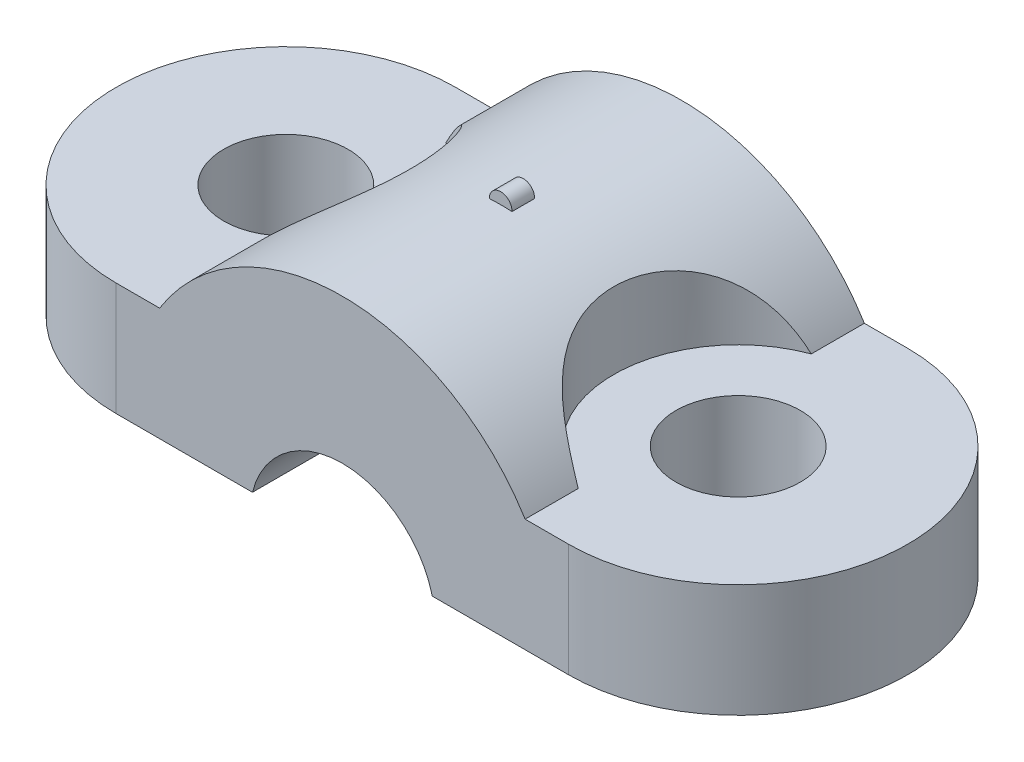
from build123d import *

# Parameters (mm, degrees)
BOSS_EXTRUDE1_DEPTH = 9.5
SKETCH1_3_R         = 2.75
BOSS_EXTRUDE2_DEPTH = 5
CUT_EXTRUDE2_DEPTH  = 25.929901725
BOSS_EXTRUDE3_DEPTH = 0.5


with BuildPart() as part:
    # Sketch1 → Boss-Extrude1 (new body)
    with BuildSketch(Plane(origin=(0, 0, 0), x_dir=(1, 0, 0), z_dir=(0, 1, 0))):
        with BuildLine():
            Line((8.08, 7.5), (-8.08, 7.5))
            Line((-8.08, 7.5), (-8.08, 5.153988747))
            ThreePointArc((-8.08, 5.153988747), (-4.5, 0), (-8.08, -5.153988747))
            Line((-8.08, -5.153988747), (-8.08, -7.5))
            Line((-8.08, -7.5), (8.08, -7.5))
            Line((8.08, -7.5), (8.08, -5.153988747))
            ThreePointArc((8.08, -5.153988747), (4.5, 0), (8.08, 5.153988747))
            Line((8.08, 5.153988747), (8.08, 7.5))
        make_face()
    extrude(amount=BOSS_EXTRUDE1_DEPTH)

    # Sketch1_3 → Boss-Extrude2 (add)
    # profile 1 of 2: a face of its own
    with BuildSketch(Plane(origin=(0, 0, 0), x_dir=(1, 0, 0), z_dir=(0, 1, 0))):
        with BuildLine():
            Line((-8.08, 5.153988747), (-8.08, 7.5))
            Line((-8.08, 7.5), (-10, 7.5))
            ThreePointArc((-10, 7.5), (-17.5, 0), (-10, -7.5))
            Line((-10, -7.5), (-8.08, -7.5))
            Line((-8.08, -7.5), (-8.08, -5.153988747))
            ThreePointArc((-8.08, -5.153988747), (-4.5, 0), (-8.08, 5.153988747))
        make_face()
        with Locations((-10, 0)):
            Circle(SKETCH1_3_R, mode=Mode.SUBTRACT)
    # profile 2 of 2: a face of its own
    with BuildSketch(Plane(origin=(0, 0, 0), x_dir=(1, 0, 0), z_dir=(0, 1, 0))):
        with BuildLine():
            Line((10, 7.5), (8.08, 7.5))
            Line((8.08, 7.5), (8.08, 5.153988747))
            ThreePointArc((8.08, 5.153988747), (4.5, 0), (8.08, -5.153988747))
            Line((8.08, -5.153988747), (8.08, -7.5))
            Line((8.08, -7.5), (10, -7.5))
            ThreePointArc((10, -7.5), (17.5, 0), (10, 7.5))
        make_face()
        with Locations((10, 0)):
            Circle(SKETCH1_3_R, mode=Mode.SUBTRACT)
    extrude(amount=BOSS_EXTRUDE2_DEPTH)

    # Sketch3 → Cut-Extrude2 (cut, through all)
    with BuildSketch(Plane.XY.offset(7.5)):
        with BuildLine():
            Line((1.6e-08, 9.5), (-8.08, 9.5))
            Line((-8.08, 9.5), (-8.08, 5))
            ThreePointArc((-8.08, 5), (-4.624294534, 8.299133313), (1.6e-08, 9.5))
        make_face()
        with BuildLine():
            Line((8.08, 9.5), (1.6e-08, 9.5))
            ThreePointArc((1.6e-08, 9.5), (4.624294548, 8.299133305), (8.08, 5))
            Line((8.08, 5), (8.08, 9.5))
        make_face()
        with BuildLine():
            Line((-3.97617907, 0), (3.97617907, 0))
            ThreePointArc((3.97617907, 0), (0, 3.1), (-3.97617907, 0))
        make_face()
    extrude(amount=-CUT_EXTRUDE2_DEPTH, mode=Mode.SUBTRACT)

    # Sketch7 → Boss-Extrude3 (add, symmetric)
    with BuildSketch(Plane.XY):
        with BuildLine():
            ThreePointArc((-0.499826987, 9.486847705), (0, 9.5), (0.499826987, 9.486847705))
            ThreePointArc((0.499826987, 9.486847705), (0, 10), (-0.499826987, 9.486847705))
        make_face()
    extrude(amount=BOSS_EXTRUDE3_DEPTH, both=True)


solid = part.part
